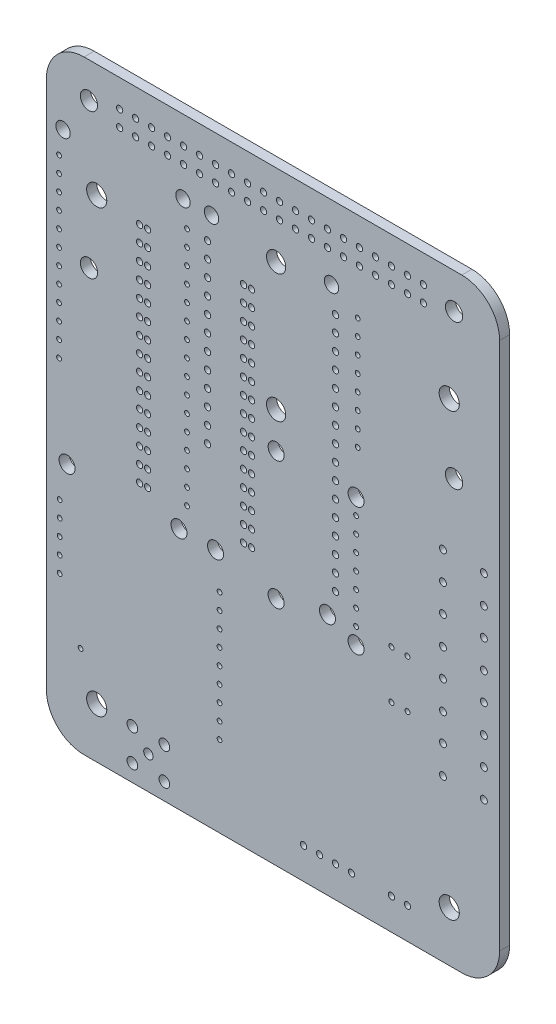
from build123d import *

# Parameters (mm, degrees)
SKETCH1_R           = 1.375
SKETCH1_R_2         = 0.5
SKETCH1_R_3         = 1.6
SKETCH1_R_4         = 0.381
SKETCH1_R_5         = 1.143
SKETCH1_R_6         = 1.524
SKETCH1_R_7         = 0.55
SKETCH1_R_8         = 1.27
SKETCH1_R_9         = 0.4
SKETCH1_R_10        = 0.85
SKETCH1_R_11        = 0.75
BOSS_EXTRUDE1_DEPTH = 1.6


with BuildPart() as part:
    # Sketch1 → Boss-Extrude1 (new body)
    with BuildSketch(Plane.XY.offset(1.6)):
        with BuildLine():
            Line((35, -118), (95, -118))
            ThreePointArc((95, -118), (99.242640687, -116.242640687), (101, -112))
            Line((101, -112), (101, -28))
            ThreePointArc((101, -28), (99.242640687, -23.757359313), (95, -22))
            Line((95, -22), (35, -22))
            ThreePointArc((35, -22), (30.757359313, -23.757359313), (29, -28))
            Line((29, -28), (29, -112))
            ThreePointArc((29, -112), (30.757359313, -116.242640687), (35, -118))
        make_face()
        with Locations((93.77, -27.62)):
            Circle(SKETCH1_R, mode=Mode.SUBTRACT)
        with Locations((88.9, -26.35)):
            Circle(SKETCH1_R_2, mode=Mode.SUBTRACT)
        with Locations((86.36, -26.35)):
            Circle(SKETCH1_R_2, mode=Mode.SUBTRACT)
        with Locations((88.9, -28.89)):
            Circle(SKETCH1_R_2, mode=Mode.SUBTRACT)
        with Locations((86.36, -28.89)):
            Circle(SKETCH1_R_2, mode=Mode.SUBTRACT)
        with Locations((83.82, -26.35)):
            Circle(SKETCH1_R_2, mode=Mode.SUBTRACT)
        with Locations((83.82, -28.89)):
            Circle(SKETCH1_R_2, mode=Mode.SUBTRACT)
        with Locations((93, -40)):
            Circle(SKETCH1_R_3, mode=Mode.SUBTRACT)
        with Locations((81.28, -26.35)):
            Circle(SKETCH1_R_2, mode=Mode.SUBTRACT)
        with Locations((78.74, -26.35)):
            Circle(SKETCH1_R_2, mode=Mode.SUBTRACT)
        with Locations((81.28, -28.89)):
            Circle(SKETCH1_R_2, mode=Mode.SUBTRACT)
        with Locations((78.74, -28.89)):
            Circle(SKETCH1_R_2, mode=Mode.SUBTRACT)
        with Locations((76.2, -26.35)):
            Circle(SKETCH1_R_2, mode=Mode.SUBTRACT)
        with Locations((73.66, -26.35)):
            Circle(SKETCH1_R_2, mode=Mode.SUBTRACT)
        with Locations((76.2, -28.89)):
            Circle(SKETCH1_R_2, mode=Mode.SUBTRACT)
        with Locations((73.66, -28.89)):
            Circle(SKETCH1_R_2, mode=Mode.SUBTRACT)
        with Locations((78.454, -36.195)):
            Circle(SKETCH1_R_4, mode=Mode.SUBTRACT)
        with Locations((74.295, -33.655)):
            Circle(SKETCH1_R_5, mode=Mode.SUBTRACT)
        with Locations((71.12, -26.35)):
            Circle(SKETCH1_R_2, mode=Mode.SUBTRACT)
        with Locations((71.12, -28.89)):
            Circle(SKETCH1_R_2, mode=Mode.SUBTRACT)
        with Locations((68.58, -26.35)):
            Circle(SKETCH1_R_2, mode=Mode.SUBTRACT)
        with Locations((66.04, -26.35)):
            Circle(SKETCH1_R_2, mode=Mode.SUBTRACT)
        with Locations((68.58, -28.89)):
            Circle(SKETCH1_R_2, mode=Mode.SUBTRACT)
        with Locations((66.04, -28.89)):
            Circle(SKETCH1_R_2, mode=Mode.SUBTRACT)
        with Locations((65.5, -34.925)):
            Circle(SKETCH1_R_6, mode=Mode.SUBTRACT)
        with Locations((78.454, -38.735)):
            Circle(SKETCH1_R_4, mode=Mode.SUBTRACT)
        with Locations((78.454, -41.275)):
            Circle(SKETCH1_R_4, mode=Mode.SUBTRACT)
        with Locations((74.93, -37.465)):
            Circle(SKETCH1_R_2, mode=Mode.SUBTRACT)
        with Locations((74.93, -40.005)):
            Circle(SKETCH1_R_2, mode=Mode.SUBTRACT)
        with Locations((74.93, -42.545)):
            Circle(SKETCH1_R_2, mode=Mode.SUBTRACT)
        with Locations((78.454, -43.815)):
            Circle(SKETCH1_R_4, mode=Mode.SUBTRACT)
        with Locations((78.454, -46.355)):
            Circle(SKETCH1_R_4, mode=Mode.SUBTRACT)
        with Locations((74.93, -45.085)):
            Circle(SKETCH1_R_2, mode=Mode.SUBTRACT)
        with Locations((74.93, -47.625)):
            Circle(SKETCH1_R_2, mode=Mode.SUBTRACT)
        with Locations((93.77, -50.62)):
            Circle(SKETCH1_R, mode=Mode.SUBTRACT)
        with Locations((98.5, -61.25)):
            Circle(SKETCH1_R_7, mode=Mode.SUBTRACT)
        with Locations((92, -61.25)):
            Circle(SKETCH1_R_7, mode=Mode.SUBTRACT)
        with Locations((98.5, -65.75)):
            Circle(SKETCH1_R_7, mode=Mode.SUBTRACT)
        with Locations((98.5, -70.14)):
            Circle(SKETCH1_R_7, mode=Mode.SUBTRACT)
        with Locations((92, -65.75)):
            Circle(SKETCH1_R_7, mode=Mode.SUBTRACT)
        with Locations((92, -70.14)):
            Circle(SKETCH1_R_7, mode=Mode.SUBTRACT)
        with Locations((78.454, -48.895)):
            Circle(SKETCH1_R_4, mode=Mode.SUBTRACT)
        with Locations((78.454, -51.435)):
            Circle(SKETCH1_R_4, mode=Mode.SUBTRACT)
        with Locations((78.454, -53.975)):
            Circle(SKETCH1_R_4, mode=Mode.SUBTRACT)
        with Locations((74.93, -50.165)):
            Circle(SKETCH1_R_2, mode=Mode.SUBTRACT)
        with Locations((74.93, -52.705)):
            Circle(SKETCH1_R_2, mode=Mode.SUBTRACT)
        with Locations((74.93, -55.245)):
            Circle(SKETCH1_R_2, mode=Mode.SUBTRACT)
        with Locations((74.93, -57.785)):
            Circle(SKETCH1_R_2, mode=Mode.SUBTRACT)
        with Locations((65.5, -55.245)):
            Circle(SKETCH1_R_6, mode=Mode.SUBTRACT)
        with Locations((78.2, -60.96)):
            Circle(SKETCH1_R_8, mode=Mode.SUBTRACT)
        with Locations((78.2, -63.5)):
            Circle(SKETCH1_R_4, mode=Mode.SUBTRACT)
        with Locations((74.93, -60.325)):
            Circle(SKETCH1_R_2, mode=Mode.SUBTRACT)
        with Locations((74.93, -62.865)):
            Circle(SKETCH1_R_2, mode=Mode.SUBTRACT)
        with Locations((78.2, -66.04)):
            Circle(SKETCH1_R_4, mode=Mode.SUBTRACT)
        with Locations((78.2, -68.58)):
            Circle(SKETCH1_R_4, mode=Mode.SUBTRACT)
        with Locations((74.93, -65.405)):
            Circle(SKETCH1_R_2, mode=Mode.SUBTRACT)
        with Locations((74.93, -67.945)):
            Circle(SKETCH1_R_2, mode=Mode.SUBTRACT)
        with Locations((74.93, -70.485)):
            Circle(SKETCH1_R_2, mode=Mode.SUBTRACT)
        with Locations((65.5, -60.96)):
            Circle(SKETCH1_R_8, mode=Mode.SUBTRACT)
        with Locations((63.5, -26.35)):
            Circle(SKETCH1_R_2, mode=Mode.SUBTRACT)
        with Locations((60.96, -26.35)):
            Circle(SKETCH1_R_2, mode=Mode.SUBTRACT)
        with Locations((63.5, -28.89)):
            Circle(SKETCH1_R_2, mode=Mode.SUBTRACT)
        with Locations((60.96, -28.89)):
            Circle(SKETCH1_R_2, mode=Mode.SUBTRACT)
        with Locations((58.42, -26.35)):
            Circle(SKETCH1_R_2, mode=Mode.SUBTRACT)
        with Locations((58.42, -28.89)):
            Circle(SKETCH1_R_2, mode=Mode.SUBTRACT)
        with Locations((55.88, -26.35)):
            Circle(SKETCH1_R_2, mode=Mode.SUBTRACT)
        with Locations((53.34, -26.35)):
            Circle(SKETCH1_R_2, mode=Mode.SUBTRACT)
        with Locations((55.88, -28.89)):
            Circle(SKETCH1_R_2, mode=Mode.SUBTRACT)
        with Locations((53.34, -28.89)):
            Circle(SKETCH1_R_2, mode=Mode.SUBTRACT)
        with Locations((50.8, -26.35)):
            Circle(SKETCH1_R_2, mode=Mode.SUBTRACT)
        with Locations((48.26, -26.35)):
            Circle(SKETCH1_R_2, mode=Mode.SUBTRACT)
        with Locations((50.8, -28.89)):
            Circle(SKETCH1_R_2, mode=Mode.SUBTRACT)
        with Locations((48.26, -28.89)):
            Circle(SKETCH1_R_2, mode=Mode.SUBTRACT)
        with Locations((55.245, -33.655)):
            Circle(SKETCH1_R_5, mode=Mode.SUBTRACT)
        with Locations((50.705, -33.655)):
            Circle(SKETCH1_R_5, mode=Mode.SUBTRACT)
        with Locations((61.595, -40.64)):
            Circle(SKETCH1_R_2, mode=Mode.SUBTRACT)
        with Locations((60.325, -40.64)):
            Circle(SKETCH1_R_2, mode=Mode.SUBTRACT)
        with Locations((61.595, -43.18)):
            Circle(SKETCH1_R_2, mode=Mode.SUBTRACT)
        with Locations((61.595, -45.72)):
            Circle(SKETCH1_R_2, mode=Mode.SUBTRACT)
        with Locations((61.595, -48.26)):
            Circle(SKETCH1_R_2, mode=Mode.SUBTRACT)
        with Locations((60.325, -43.18)):
            Circle(SKETCH1_R_2, mode=Mode.SUBTRACT)
        with Locations((60.325, -45.72)):
            Circle(SKETCH1_R_2, mode=Mode.SUBTRACT)
        with Locations((60.325, -48.26)):
            Circle(SKETCH1_R_2, mode=Mode.SUBTRACT)
        with Locations((54.61, -37.465)):
            Circle(SKETCH1_R_2, mode=Mode.SUBTRACT)
        with Locations((54.61, -40.005)):
            Circle(SKETCH1_R_2, mode=Mode.SUBTRACT)
        with Locations((54.61, -42.545)):
            Circle(SKETCH1_R_2, mode=Mode.SUBTRACT)
        with Locations((51.34, -37.465)):
            Circle(SKETCH1_R_4, mode=Mode.SUBTRACT)
        with Locations((51.34, -40.005)):
            Circle(SKETCH1_R_4, mode=Mode.SUBTRACT)
        with Locations((51.34, -42.545)):
            Circle(SKETCH1_R_4, mode=Mode.SUBTRACT)
        with Locations((54.61, -45.085)):
            Circle(SKETCH1_R_2, mode=Mode.SUBTRACT)
        with Locations((54.61, -47.625)):
            Circle(SKETCH1_R_2, mode=Mode.SUBTRACT)
        with Locations((51.34, -45.085)):
            Circle(SKETCH1_R_4, mode=Mode.SUBTRACT)
        with Locations((51.34, -47.625)):
            Circle(SKETCH1_R_4, mode=Mode.SUBTRACT)
        with Locations((45.72, -26.35)):
            Circle(SKETCH1_R_2, mode=Mode.SUBTRACT)
        with Locations((45.72, -28.89)):
            Circle(SKETCH1_R_2, mode=Mode.SUBTRACT)
        with Locations((43.18, -26.35)):
            Circle(SKETCH1_R_2, mode=Mode.SUBTRACT)
        with Locations((40.64, -26.35)):
            Circle(SKETCH1_R_2, mode=Mode.SUBTRACT)
        with Locations((43.18, -28.89)):
            Circle(SKETCH1_R_2, mode=Mode.SUBTRACT)
        with Locations((40.64, -28.89)):
            Circle(SKETCH1_R_2, mode=Mode.SUBTRACT)
        with Locations((35.77, -27.62)):
            Circle(SKETCH1_R, mode=Mode.SUBTRACT)
        with Locations((31.655, -33.655)):
            Circle(SKETCH1_R_5, mode=Mode.SUBTRACT)
        with Locations((45.085, -40.64)):
            Circle(SKETCH1_R_2, mode=Mode.SUBTRACT)
        with Locations((43.815, -40.64)):
            Circle(SKETCH1_R_2, mode=Mode.SUBTRACT)
        with Locations((45.085, -43.18)):
            Circle(SKETCH1_R_2, mode=Mode.SUBTRACT)
        with Locations((43.815, -43.18)):
            Circle(SKETCH1_R_2, mode=Mode.SUBTRACT)
        with Locations((45.085, -45.72)):
            Circle(SKETCH1_R_2, mode=Mode.SUBTRACT)
        with Locations((43.815, -45.72)):
            Circle(SKETCH1_R_2, mode=Mode.SUBTRACT)
        with Locations((45.085, -48.26)):
            Circle(SKETCH1_R_2, mode=Mode.SUBTRACT)
        with Locations((43.815, -48.26)):
            Circle(SKETCH1_R_2, mode=Mode.SUBTRACT)
        with Locations((37, -40)):
            Circle(SKETCH1_R_3, mode=Mode.SUBTRACT)
        with Locations((31.02, -37.465)):
            Circle(SKETCH1_R_4, mode=Mode.SUBTRACT)
        with Locations((31.02, -40.005)):
            Circle(SKETCH1_R_4, mode=Mode.SUBTRACT)
        with Locations((31.02, -42.545)):
            Circle(SKETCH1_R_4, mode=Mode.SUBTRACT)
        with Locations((31.02, -45.085)):
            Circle(SKETCH1_R_4, mode=Mode.SUBTRACT)
        with Locations((31.02, -47.625)):
            Circle(SKETCH1_R_4, mode=Mode.SUBTRACT)
        with Locations((61.595, -50.8)):
            Circle(SKETCH1_R_2, mode=Mode.SUBTRACT)
        with Locations((61.595, -53.34)):
            Circle(SKETCH1_R_2, mode=Mode.SUBTRACT)
        with Locations((60.325, -50.8)):
            Circle(SKETCH1_R_2, mode=Mode.SUBTRACT)
        with Locations((60.325, -53.34)):
            Circle(SKETCH1_R_2, mode=Mode.SUBTRACT)
        with Locations((61.595, -55.88)):
            Circle(SKETCH1_R_2, mode=Mode.SUBTRACT)
        with Locations((61.595, -58.42)):
            Circle(SKETCH1_R_2, mode=Mode.SUBTRACT)
        with Locations((60.325, -55.88)):
            Circle(SKETCH1_R_2, mode=Mode.SUBTRACT)
        with Locations((60.325, -58.42)):
            Circle(SKETCH1_R_2, mode=Mode.SUBTRACT)
        with Locations((54.61, -50.165)):
            Circle(SKETCH1_R_2, mode=Mode.SUBTRACT)
        with Locations((54.61, -52.705)):
            Circle(SKETCH1_R_2, mode=Mode.SUBTRACT)
        with Locations((51.34, -50.165)):
            Circle(SKETCH1_R_4, mode=Mode.SUBTRACT)
        with Locations((51.34, -52.705)):
            Circle(SKETCH1_R_4, mode=Mode.SUBTRACT)
        with Locations((54.61, -55.245)):
            Circle(SKETCH1_R_2, mode=Mode.SUBTRACT)
        with Locations((54.61, -57.785)):
            Circle(SKETCH1_R_2, mode=Mode.SUBTRACT)
        with Locations((51.34, -55.245)):
            Circle(SKETCH1_R_4, mode=Mode.SUBTRACT)
        with Locations((51.34, -57.785)):
            Circle(SKETCH1_R_4, mode=Mode.SUBTRACT)
        with Locations((61.595, -60.96)):
            Circle(SKETCH1_R_2, mode=Mode.SUBTRACT)
        with Locations((61.595, -63.5)):
            Circle(SKETCH1_R_2, mode=Mode.SUBTRACT)
        with Locations((60.325, -60.96)):
            Circle(SKETCH1_R_2, mode=Mode.SUBTRACT)
        with Locations((60.325, -63.5)):
            Circle(SKETCH1_R_2, mode=Mode.SUBTRACT)
        with Locations((61.595, -66.04)):
            Circle(SKETCH1_R_2, mode=Mode.SUBTRACT)
        with Locations((61.595, -68.58)):
            Circle(SKETCH1_R_2, mode=Mode.SUBTRACT)
        with Locations((60.325, -66.04)):
            Circle(SKETCH1_R_2, mode=Mode.SUBTRACT)
        with Locations((60.325, -68.58)):
            Circle(SKETCH1_R_2, mode=Mode.SUBTRACT)
        with Locations((54.61, -60.325)):
            Circle(SKETCH1_R_2, mode=Mode.SUBTRACT)
        with Locations((54.61, -62.865)):
            Circle(SKETCH1_R_2, mode=Mode.SUBTRACT)
        with Locations((51.34, -60.325)):
            Circle(SKETCH1_R_4, mode=Mode.SUBTRACT)
        with Locations((51.34, -62.865)):
            Circle(SKETCH1_R_4, mode=Mode.SUBTRACT)
        with Locations((54.61, -65.405)):
            Circle(SKETCH1_R_2, mode=Mode.SUBTRACT)
        with Locations((51.34, -65.405)):
            Circle(SKETCH1_R_4, mode=Mode.SUBTRACT)
        with Locations((51.34, -67.945)):
            Circle(SKETCH1_R_4, mode=Mode.SUBTRACT)
        with Locations((51.34, -70.485)):
            Circle(SKETCH1_R_4, mode=Mode.SUBTRACT)
        with Locations((45.085, -50.8)):
            Circle(SKETCH1_R_2, mode=Mode.SUBTRACT)
        with Locations((43.815, -50.8)):
            Circle(SKETCH1_R_2, mode=Mode.SUBTRACT)
        with Locations((45.085, -53.34)):
            Circle(SKETCH1_R_2, mode=Mode.SUBTRACT)
        with Locations((43.815, -53.34)):
            Circle(SKETCH1_R_2, mode=Mode.SUBTRACT)
        with Locations((45.085, -55.88)):
            Circle(SKETCH1_R_2, mode=Mode.SUBTRACT)
        with Locations((43.815, -55.88)):
            Circle(SKETCH1_R_2, mode=Mode.SUBTRACT)
        with Locations((45.085, -58.42)):
            Circle(SKETCH1_R_2, mode=Mode.SUBTRACT)
        with Locations((43.815, -58.42)):
            Circle(SKETCH1_R_2, mode=Mode.SUBTRACT)
        with Locations((35.77, -50.62)):
            Circle(SKETCH1_R, mode=Mode.SUBTRACT)
        with Locations((31.02, -50.165)):
            Circle(SKETCH1_R_4, mode=Mode.SUBTRACT)
        with Locations((31.02, -52.705)):
            Circle(SKETCH1_R_4, mode=Mode.SUBTRACT)
        with Locations((31.02, -55.245)):
            Circle(SKETCH1_R_4, mode=Mode.SUBTRACT)
        with Locations((31.02, -57.785)):
            Circle(SKETCH1_R_4, mode=Mode.SUBTRACT)
        with Locations((45.085, -60.96)):
            Circle(SKETCH1_R_2, mode=Mode.SUBTRACT)
        with Locations((43.815, -60.96)):
            Circle(SKETCH1_R_2, mode=Mode.SUBTRACT)
        with Locations((45.085, -63.5)):
            Circle(SKETCH1_R_2, mode=Mode.SUBTRACT)
        with Locations((43.815, -63.5)):
            Circle(SKETCH1_R_2, mode=Mode.SUBTRACT)
        with Locations((45.085, -66.04)):
            Circle(SKETCH1_R_2, mode=Mode.SUBTRACT)
        with Locations((43.815, -66.04)):
            Circle(SKETCH1_R_2, mode=Mode.SUBTRACT)
        with Locations((45.085, -68.58)):
            Circle(SKETCH1_R_2, mode=Mode.SUBTRACT)
        with Locations((43.815, -68.58)):
            Circle(SKETCH1_R_2, mode=Mode.SUBTRACT)
        with Locations((31.02, -60.325)):
            Circle(SKETCH1_R_4, mode=Mode.SUBTRACT)
        with Locations((31.02, -62.865)):
            Circle(SKETCH1_R_4, mode=Mode.SUBTRACT)
        with Locations((31.02, -65.405)):
            Circle(SKETCH1_R_4, mode=Mode.SUBTRACT)
        with Locations((98.5, -74.64)):
            Circle(SKETCH1_R_7, mode=Mode.SUBTRACT)
        with Locations((92, -74.64)):
            Circle(SKETCH1_R_7, mode=Mode.SUBTRACT)
        with Locations((98.5, -79.03)):
            Circle(SKETCH1_R_7, mode=Mode.SUBTRACT)
        with Locations((92, -79.03)):
            Circle(SKETCH1_R_7, mode=Mode.SUBTRACT)
        with Locations((86.36, -78.74)):
            Circle(SKETCH1_R_9, mode=Mode.SUBTRACT)
        with Locations((83.82, -78.74)):
            Circle(SKETCH1_R_9, mode=Mode.SUBTRACT)
        with Locations((98.5, -83.53)):
            Circle(SKETCH1_R_7, mode=Mode.SUBTRACT)
        with Locations((98.5, -87.92)):
            Circle(SKETCH1_R_7, mode=Mode.SUBTRACT)
        with Locations((92, -83.53)):
            Circle(SKETCH1_R_7, mode=Mode.SUBTRACT)
        with Locations((92, -87.92)):
            Circle(SKETCH1_R_7, mode=Mode.SUBTRACT)
        with Locations((98.5, -92.42)):
            Circle(SKETCH1_R_7, mode=Mode.SUBTRACT)
        with Locations((92, -92.42)):
            Circle(SKETCH1_R_7, mode=Mode.SUBTRACT)
        with Locations((86.36, -86.36)):
            Circle(SKETCH1_R_9, mode=Mode.SUBTRACT)
        with Locations((83.82, -86.36)):
            Circle(SKETCH1_R_9, mode=Mode.SUBTRACT)
        with Locations((78.2, -71.12)):
            Circle(SKETCH1_R_4, mode=Mode.SUBTRACT)
        with Locations((78.2, -73.66)):
            Circle(SKETCH1_R_4, mode=Mode.SUBTRACT)
        with Locations((78.2, -76.2)):
            Circle(SKETCH1_R_4, mode=Mode.SUBTRACT)
        with Locations((74.93, -73.025)):
            Circle(SKETCH1_R_2, mode=Mode.SUBTRACT)
        with Locations((74.93, -75.565)):
            Circle(SKETCH1_R_2, mode=Mode.SUBTRACT)
        with Locations((78.2, -78.74)):
            Circle(SKETCH1_R_4, mode=Mode.SUBTRACT)
        with Locations((78.2, -81.28)):
            Circle(SKETCH1_R_8, mode=Mode.SUBTRACT)
        with Locations((73.66, -79.375)):
            Circle(SKETCH1_R_8, mode=Mode.SUBTRACT)
        with Locations((65.5, -81.28)):
            Circle(SKETCH1_R_8, mode=Mode.SUBTRACT)
        with Locations((93, -110)):
            Circle(SKETCH1_R_3, mode=Mode.SUBTRACT)
        with Locations((86.36, -113.03)):
            Circle(SKETCH1_R_2, mode=Mode.SUBTRACT)
        with Locations((83.82, -113.03)):
            Circle(SKETCH1_R_2, mode=Mode.SUBTRACT)
        with Locations((77.48, -113.03)):
            Circle(SKETCH1_R_2, mode=Mode.SUBTRACT)
        with Locations((74.94, -113.03)):
            Circle(SKETCH1_R_2, mode=Mode.SUBTRACT)
        with Locations((72.4, -113.03)):
            Circle(SKETCH1_R_2, mode=Mode.SUBTRACT)
        with Locations((69.86, -113.03)):
            Circle(SKETCH1_R_2, mode=Mode.SUBTRACT)
        with Locations((61.595, -71.12)):
            Circle(SKETCH1_R_2, mode=Mode.SUBTRACT)
        with Locations((61.595, -73.66)):
            Circle(SKETCH1_R_2, mode=Mode.SUBTRACT)
        with Locations((61.595, -76.2)):
            Circle(SKETCH1_R_2, mode=Mode.SUBTRACT)
        with Locations((60.325, -71.12)):
            Circle(SKETCH1_R_2, mode=Mode.SUBTRACT)
        with Locations((60.325, -73.66)):
            Circle(SKETCH1_R_2, mode=Mode.SUBTRACT)
        with Locations((60.325, -76.2)):
            Circle(SKETCH1_R_2, mode=Mode.SUBTRACT)
        with Locations((51.34, -73.025)):
            Circle(SKETCH1_R_4, mode=Mode.SUBTRACT)
        with Locations((51.34, -75.565)):
            Circle(SKETCH1_R_4, mode=Mode.SUBTRACT)
        with Locations((55.88, -79.375)):
            Circle(SKETCH1_R_8, mode=Mode.SUBTRACT)
        with Locations((50.07, -79.375)):
            Circle(SKETCH1_R_8, mode=Mode.SUBTRACT)
        with Locations((56.515, -84.836)):
            Circle(SKETCH1_R_4, mode=Mode.SUBTRACT)
        with Locations((56.515, -87.376)):
            Circle(SKETCH1_R_4, mode=Mode.SUBTRACT)
        with Locations((56.515, -89.916)):
            Circle(SKETCH1_R_4, mode=Mode.SUBTRACT)
        with Locations((56.515, -92.456)):
            Circle(SKETCH1_R_4, mode=Mode.SUBTRACT)
        with Locations((45.085, -71.12)):
            Circle(SKETCH1_R_2, mode=Mode.SUBTRACT)
        with Locations((43.815, -71.12)):
            Circle(SKETCH1_R_2, mode=Mode.SUBTRACT)
        with Locations((45.085, -73.66)):
            Circle(SKETCH1_R_2, mode=Mode.SUBTRACT)
        with Locations((43.815, -73.66)):
            Circle(SKETCH1_R_2, mode=Mode.SUBTRACT)
        with Locations((45.085, -76.2)):
            Circle(SKETCH1_R_2, mode=Mode.SUBTRACT)
        with Locations((43.815, -76.2)):
            Circle(SKETCH1_R_2, mode=Mode.SUBTRACT)
        with Locations((32.29, -79.375)):
            Circle(SKETCH1_R_8, mode=Mode.SUBTRACT)
        with Locations((31.115, -84.836)):
            Circle(SKETCH1_R_4, mode=Mode.SUBTRACT)
        with Locations((31.115, -87.376)):
            Circle(SKETCH1_R_4, mode=Mode.SUBTRACT)
        with Locations((31.115, -89.916)):
            Circle(SKETCH1_R_4, mode=Mode.SUBTRACT)
        with Locations((31.115, -92.456)):
            Circle(SKETCH1_R_4, mode=Mode.SUBTRACT)
        with Locations((56.515, -94.996)):
            Circle(SKETCH1_R_4, mode=Mode.SUBTRACT)
        with Locations((56.515, -97.536)):
            Circle(SKETCH1_R_4, mode=Mode.SUBTRACT)
        with Locations((56.515, -100.076)):
            Circle(SKETCH1_R_4, mode=Mode.SUBTRACT)
        with Locations((56.515, -102.616)):
            Circle(SKETCH1_R_4, mode=Mode.SUBTRACT)
        with Locations((56.515, -105.156)):
            Circle(SKETCH1_R_4, mode=Mode.SUBTRACT)
        with Locations((47.752, -110.236)):
            Circle(SKETCH1_R_10, mode=Mode.SUBTRACT)
        with Locations((47.752, -115.316)):
            Circle(SKETCH1_R_10, mode=Mode.SUBTRACT)
        with Locations((31.115, -94.996)):
            Circle(SKETCH1_R_4, mode=Mode.SUBTRACT)
        with Locations((34.445, -103.632)):
            Circle(SKETCH1_R_4, mode=Mode.SUBTRACT)
        with Locations((42.672, -110.236)):
            Circle(SKETCH1_R_10, mode=Mode.SUBTRACT)
        with Locations((45.212, -112.776)):
            Circle(SKETCH1_R_11, mode=Mode.SUBTRACT)
        with Locations((42.672, -115.316)):
            Circle(SKETCH1_R_10, mode=Mode.SUBTRACT)
        with Locations((37, -110)):
            Circle(SKETCH1_R_3, mode=Mode.SUBTRACT)
    extrude(amount=-BOSS_EXTRUDE1_DEPTH)


solid = part.part
